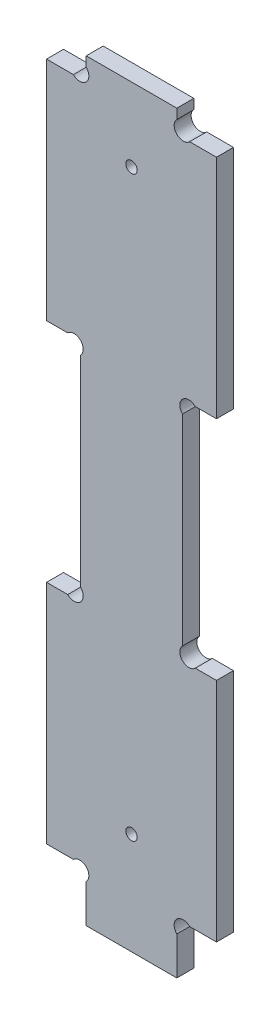
from build123d import *

# Parameters (mm, degrees)
EXTRUSION1_DEPTH        = 3
ESQUISSE2_R             = 1
ENL_V_MAT_EXTRU_1_DEPTH = 4


with BuildPart() as part:
    # Esquisse1 → Extrusion1 (new body)
    with BuildSketch(Plane.XY):
        with BuildLine():
            Line((25.2627417, 9), (30, 9))
            Line((30, 9), (30, 49))
            Line((30, 49), (26.2627417, 49))
            ThreePointArc((26.2627417, 49), (24, 49), (24, 51.2627417))
            Line((24, 51.2627417), (24, 86.7372583))
            ThreePointArc((24, 86.7372583), (24, 89), (26.2627417, 89))
            Line((26.2627417, 89), (30, 89))
            Line((30, 89), (30, 129))
            Line((30, 129), (25.2627417, 129))
            ThreePointArc((25.2627417, 129), (23, 129), (23, 131.2627417))
            Line((23, 131.2627417), (23, 133))
            Line((23, 133), (7, 133))
            Line((7, 133), (7, 131.2627417))
            ThreePointArc((7, 131.2627417), (7, 129), (4.7372583, 129))
            Line((4.7372583, 129), (0, 129))
            Line((0, 129), (0, 89))
            Line((0, 89), (3.7372583, 89))
            ThreePointArc((3.7372583, 89), (6, 89), (6, 86.7372583))
            Line((6, 86.7372583), (6, 51.2627417))
            ThreePointArc((6, 51.2627417), (6, 49), (3.7372583, 49))
            Line((3.7372583, 49), (0, 49))
            Line((0, 49), (0, 9))
            Line((0, 9), (4.7372583, 9))
            ThreePointArc((4.7372583, 9), (7, 9), (7, 6.7372583))
            Line((7, 6.7372583), (7, 0))
            Line((7, 0), (23, 0))
            Line((23, 0), (23, 6.7372583))
            ThreePointArc((23, 6.7372583), (23, 9), (25.2627417, 9))
        make_face()
    extrude(amount=EXTRUSION1_DEPTH)

    # Esquisse2 → Enlèv. mat.-Extru.1 (cut, through all)
    with BuildSketch(Plane.XY.offset(3)):
        with Locations((15, 18)):
            Circle(ESQUISSE2_R)
        with Locations((15, 120)):
            Circle(ESQUISSE2_R)
    extrude(amount=-ENL_V_MAT_EXTRU_1_DEPTH, mode=Mode.SUBTRACT)


solid = part.part
